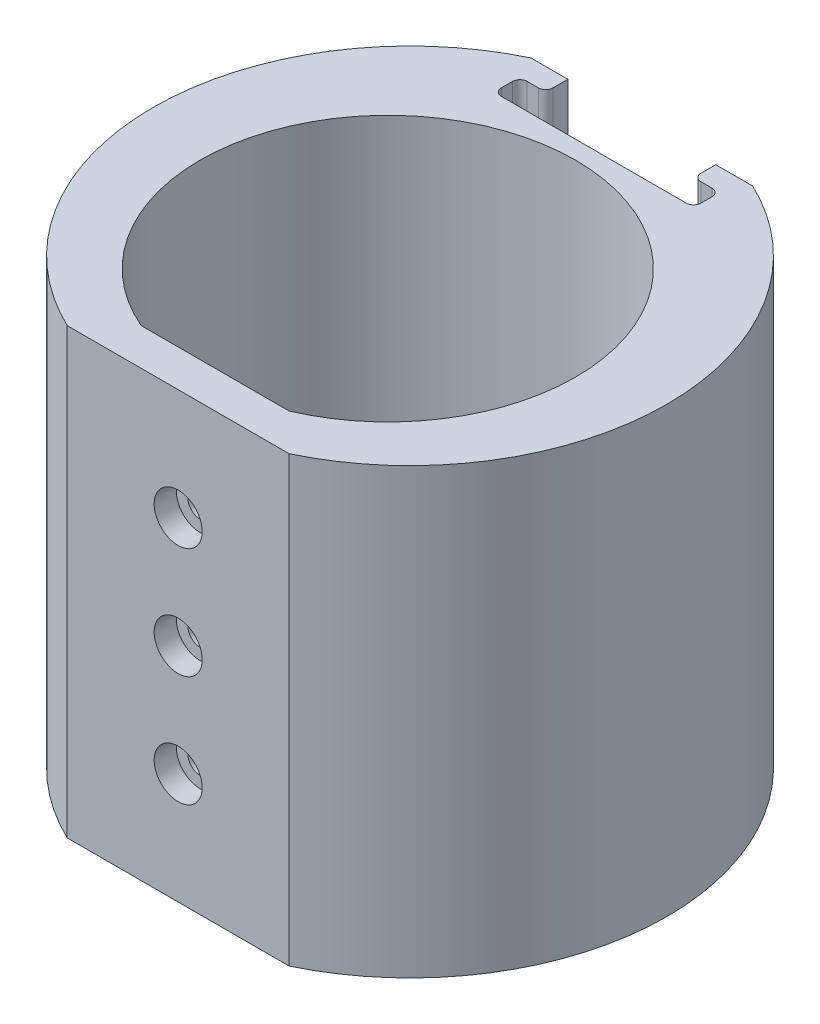
from build123d import *

# Parameters (mm, degrees)
BOSS_EXTRUDE1_DEPTH            = 30
CUT_EXTRUDE1_DEPTH             = 50
FILLET1_R                      = 1
CBORE_FOR_M3_SHCS1_D           = 3.4
CBORE_FOR_M3_SHCS1_DEPTH       = 5
CBORE_FOR_M3_SHCS1_CBORE_D     = 6.5
CBORE_FOR_M3_SHCS1_CBORE_DEPTH = 3
CBORE_FOR_M3_SHCS1_TIP         = 1.021463052


with BuildPart() as part:
    # Sketch1 → Boss-Extrude1 (new body, symmetric)
    with BuildSketch(Plane(origin=(0, 0, 0), x_dir=(1, 0, 0), z_dir=(0, 1, 0))):
        with BuildLine():
            Line((-15, -28.348661632), (15, -28.348661632))
            ThreePointArc((15, -28.348661632), (34.752533521, 3), (15, 34.348661632))
            Line((15, 34.348661632), (-15, 34.348661632))
            ThreePointArc((-15, 34.348661632), (-34.752533521, 3), (-15, -28.348661632))
        make_face()
        with BuildLine():
            Line((-10, -23.348661632), (10, -23.348661632))
            ThreePointArc((10, -23.348661632), (0, 25.4), (-10, -23.348661632))
        make_face(mode=Mode.SUBTRACT)
    extrude(amount=BOSS_EXTRUDE1_DEPTH, both=True)

    # Sketch4 → Cut-Extrude1 (cut)
    with BuildSketch(Plane(origin=(0, 30, 0), x_dir=(1, 0, 0), z_dir=(0, 1, 0))):
        Polygon((-10, 34.348661632), (-10, 31.348661632), (-13.5, 31.348661632), (-13.5, 27.848661632), (13.5, 27.848661632), (13.5, 31.348661632), (10, 31.348661632), (10, 34.348661632), align=None)
    extrude(amount=-CUT_EXTRUDE1_DEPTH, mode=Mode.SUBTRACT)

    # Fillet1
    fillet1_edges = [part.edges().sort_by_distance(p)[0] for p in [
        (10, 5, -31.348661632),
        (13.5, 5, -31.348661632),
        (13.5, 5, -27.848661632),
        (-13.5, 5, -27.848661632),
        (-13.5, 5, -31.348661632),
        (-10, 5, -31.348661632),
    ]]
    fillet(fillet1_edges, radius=FILLET1_R)

    # CBORE for M3 SHCS1
    with Locations(Plane.XY.offset(28.348661632)):
        with Locations((0, 0), (0, 15), (0, -15)):
            CounterBoreHole(CBORE_FOR_M3_SHCS1_D / 2, CBORE_FOR_M3_SHCS1_CBORE_D / 2, CBORE_FOR_M3_SHCS1_CBORE_DEPTH, depth=CBORE_FOR_M3_SHCS1_DEPTH)
            with Locations((0, 0, -(CBORE_FOR_M3_SHCS1_DEPTH + CBORE_FOR_M3_SHCS1_TIP / 2))):  # 118° drill point
                Cone(0, CBORE_FOR_M3_SHCS1_D / 2, CBORE_FOR_M3_SHCS1_TIP, mode=Mode.SUBTRACT)


solid = part.part
